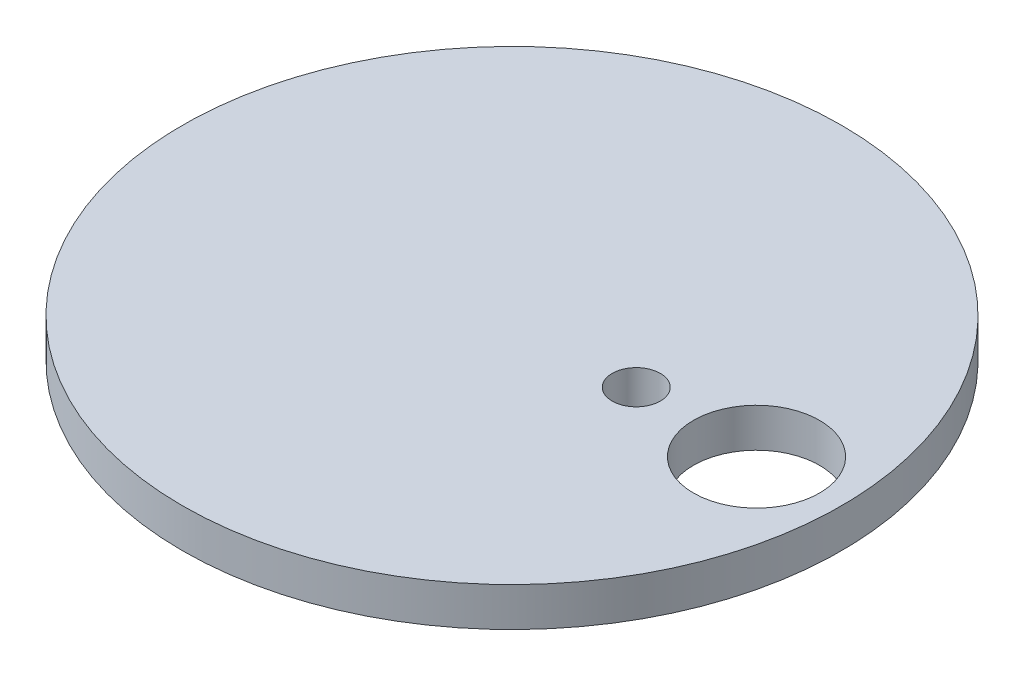
from build123d import *

# Parameters (mm, degrees)
SKETCH1_R           = 4.1275
SKETCH1_R_2         = 2.8575
BOSS_EXTRUDE1_DEPTH = 3.6068
SKETCH3_R           = 17.399
SKETCH3_R_2         = 3.3274
SKETCH3_R_3         = 1.27
BOSS_EXTRUDE2_DEPTH = 2.0574


with BuildPart() as part:
    # Sketch1 → Boss-Extrude1 (new body)
    with BuildSketch(Plane(origin=(0, 0, 0), x_dir=(1, 0, 0), z_dir=(0, 1, 0))):
        Circle(SKETCH1_R)
        Circle(SKETCH1_R_2, mode=Mode.SUBTRACT)
    extrude(amount=BOSS_EXTRUDE1_DEPTH)

    # Sketch3 → Boss-Extrude2 (add)
    with BuildSketch(Plane(origin=(0, 3.6068, 0), x_dir=(1, 0, 0), z_dir=(0, 1, 0))):
        Circle(SKETCH3_R)
        with Locations((12.90955, 0)):
            Circle(SKETCH3_R_2, mode=Mode.SUBTRACT)
        with Locations((6.55955, 0)):
            Circle(SKETCH3_R_3, mode=Mode.SUBTRACT)
    extrude(amount=BOSS_EXTRUDE2_DEPTH)


solid = part.part
